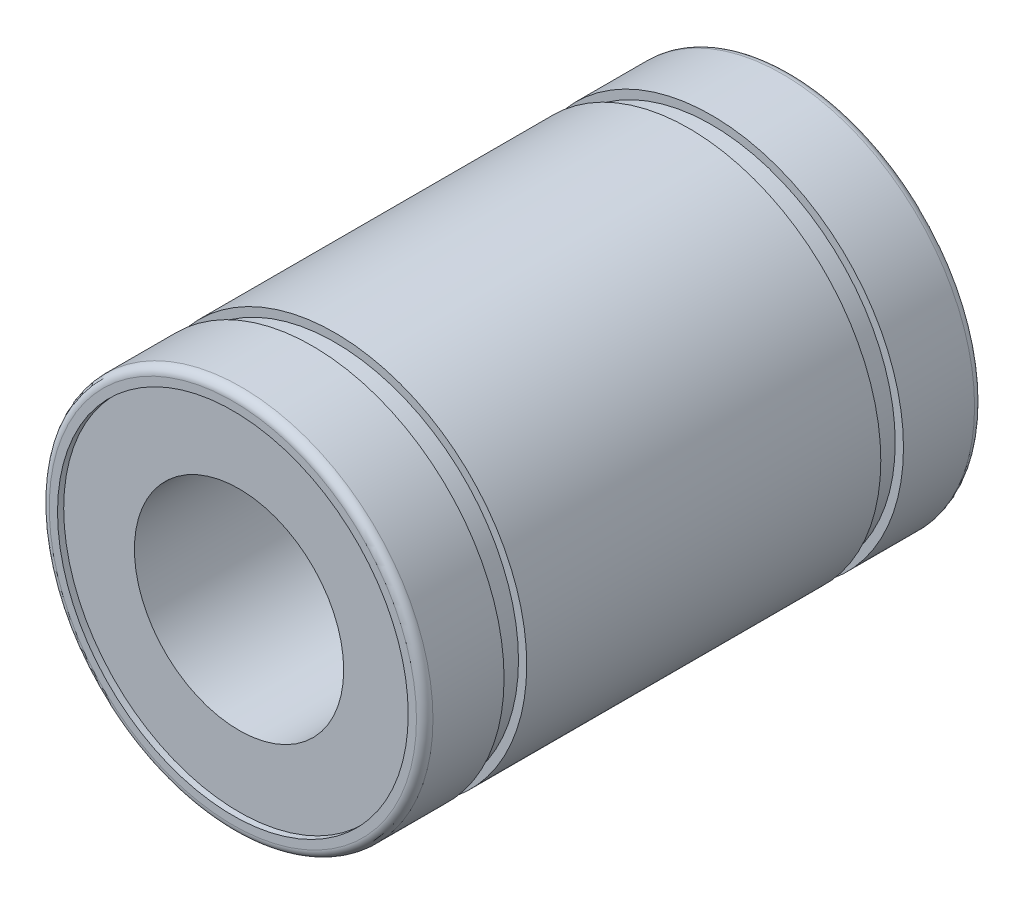
from build123d import *

# Parameters (mm, degrees)
SKETCH3_W = 1.3
SKETCH3_H = 0.473161305


with BuildPart() as part:
    # Sketch2 → Body (revolve)
    with BuildSketch(Plane(origin=(0, 0, 0), x_dir=(0, 0, -1), z_dir=(1, 0, 0))):
        with BuildLine():
            Line((-15.645349183, 10.053677391), (-16, 10.053677391))
            Line((-16, 10.053677391), (-16, 10.526838695))
            ThreePointArc((-16, 10.526838695), (-15.861414262, 10.861414262), (-15.526838695, 11))
            Line((-15.526838695, 11), (15.526838695, 11))
            ThreePointArc((15.526838695, 11), (15.861414262, 10.861414262), (16, 10.526838695))
            Line((16, 10.526838695), (16, 10.053677391))
            Line((16, 10.053677391), (15.645349183, 10.053677391))
            Line((15.645349183, 10.053677391), (15.645349183, 6))
            Line((15.645349183, 6), (-15.645349183, 6))
            Line((-15.645349183, 6), (-15.645349183, 10.053677391))
        make_face()
    revolve(axis=Axis((0, 0, 16), (0, 0, -1)))

    # Sketch3 → Track (revolve, cut)
    with BuildSketch(Plane(origin=(0, 0, 0), x_dir=(0, 0, -1), z_dir=(1, 0, 0))):
        with Locations((10.8, 10.763419348)):
            Rectangle(SKETCH3_W, SKETCH3_H)
        with Locations((-10.8, 10.763419348)):
            Rectangle(SKETCH3_W, SKETCH3_H)
    revolve(axis=Axis((0, 0, 16), (0, 0, -1)), mode=Mode.SUBTRACT)


solid = part.part
